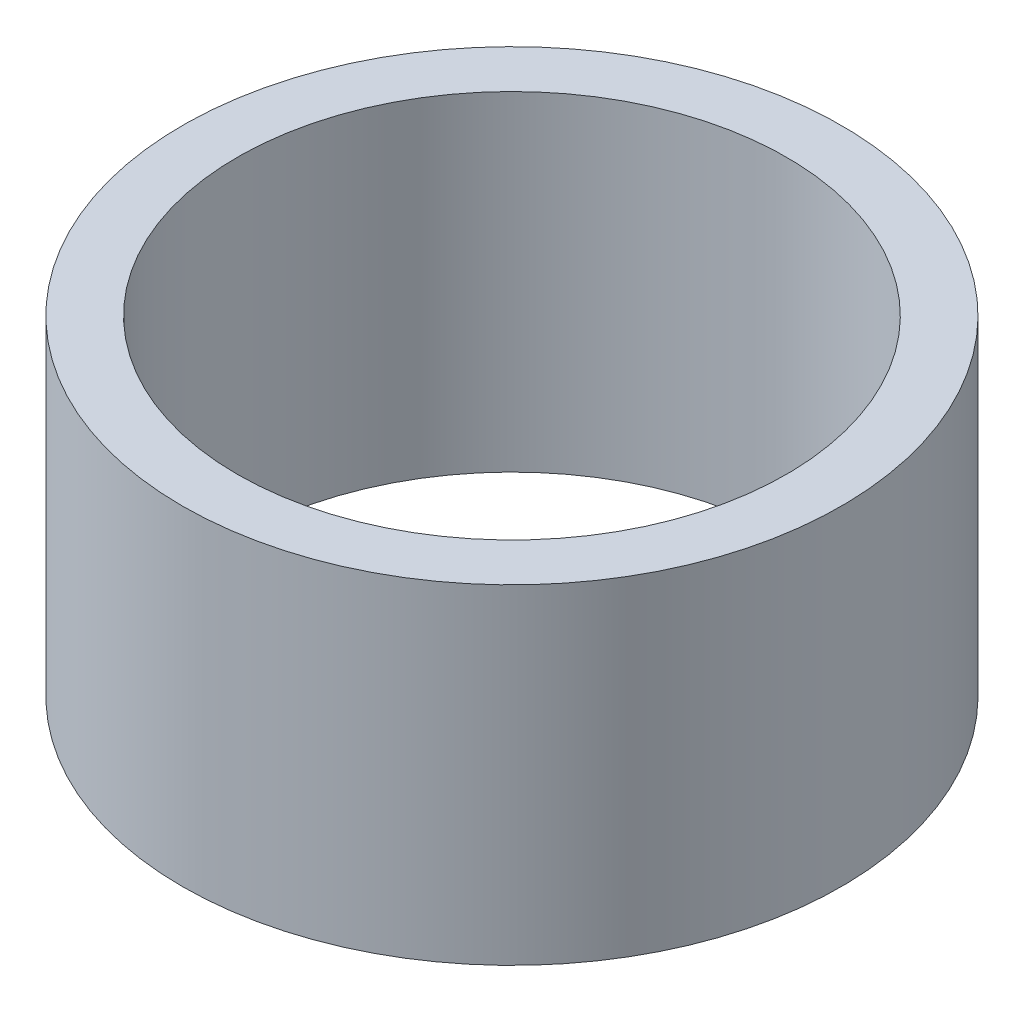
from build123d import *

# Parameters (mm, degrees)
SKETCH1_R           = 6
SKETCH1_R_2         = 5
BOSS_EXTRUDE1_DEPTH = 6


with BuildPart() as part:
    # Sketch1 → Boss-Extrude1 (new body)
    with BuildSketch(Plane(origin=(0, 0, 0), x_dir=(1, 0, 0), z_dir=(0, 1, 0))):
        Circle(SKETCH1_R)
        Circle(SKETCH1_R_2, mode=Mode.SUBTRACT)
    extrude(amount=BOSS_EXTRUDE1_DEPTH)


solid = part.part
